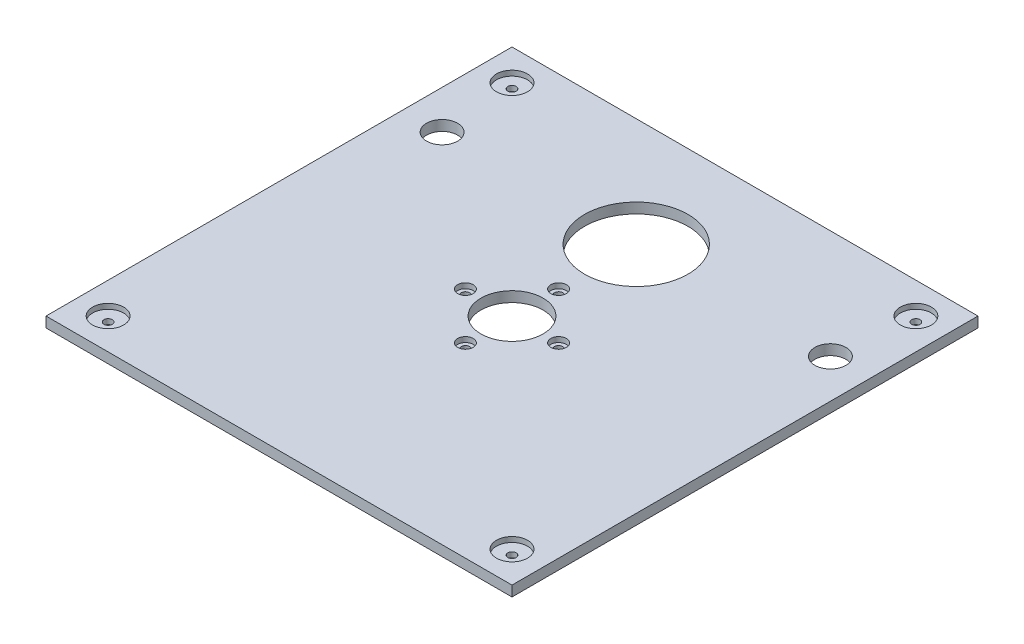
from build123d import *

# Parameters (mm, degrees)
CROQUIS1_W              = 450
CROQUIS1_H              = 450
CROQUIS1_R              = 30
CROQUIS1_R_2            = 50
CROQUIS1_R_3            = 15
SALIENTE_EXTRUIR1_DEPTH = 10
CROQUIS7_R              = 15
CROQUIS7_R_2            = 7.5
CORTAR_EXTRUIR6_DEPTH   = 5
CROQUIS8_R              = 4
CORTAR_EXTRUIR7_DEPTH   = 5


with BuildPart() as part:
    # Croquis1 → Saliente-Extruir1 (new body)
    with BuildSketch(Plane(origin=(0, 0, 0), x_dir=(1, 0, 0), z_dir=(0, 1, 0))):
        Rectangle(CROQUIS1_W, CROQUIS1_H)
        Circle(CROQUIS1_R, mode=Mode.SUBTRACT)
        with Locations((0, 120)):
            Circle(CROQUIS1_R_2, mode=Mode.SUBTRACT)
        with Locations((-187.5, 120)):
            Circle(CROQUIS1_R_3, mode=Mode.SUBTRACT)
        with Locations((187.5, 120)):
            Circle(CROQUIS1_R_3, mode=Mode.SUBTRACT)
    extrude(amount=SALIENTE_EXTRUIR1_DEPTH)

    # Croquis7 → Cortar-Extruir6 (cut)
    with BuildSketch(Plane(origin=(0, 10, 0), x_dir=(1, 0, 0), z_dir=(0, 1, 0))):
        with Locations((-195, 195)):
            Circle(CROQUIS7_R)
        with Locations((195, 195)):
            Circle(CROQUIS7_R)
        with Locations((195, -195)):
            Circle(CROQUIS7_R)
        with Locations((-195, -195)):
            Circle(CROQUIS7_R)
        with Locations((-45, 0)):
            Circle(CROQUIS7_R_2)
        with Locations((0, 45)):
            Circle(CROQUIS7_R_2)
        with Locations((0, -45)):
            Circle(CROQUIS7_R_2)
        with Locations((45, 0)):
            Circle(CROQUIS7_R_2)
    extrude(amount=-CORTAR_EXTRUIR6_DEPTH, mode=Mode.SUBTRACT)

    # Croquis8 → Cortar-Extruir7 (cut)
    with BuildSketch(Plane(origin=(0, 5, 0), x_dir=(1, 0, 0), z_dir=(0, 1, 0))):
        with Locations((195, -195)):
            Circle(CROQUIS8_R)
        with Locations((-195, -195)):
            Circle(CROQUIS8_R)
        with Locations((-45, 0)):
            Circle(CROQUIS8_R)
        with Locations((45, 0)):
            Circle(CROQUIS8_R)
        with Locations((0, -45)):
            Circle(CROQUIS8_R)
        with Locations((0, 45)):
            Circle(CROQUIS8_R)
        with Locations((195, 195)):
            Circle(CROQUIS8_R)
        with Locations((-195, 195)):
            Circle(CROQUIS8_R)
    extrude(amount=-CORTAR_EXTRUIR7_DEPTH, mode=Mode.SUBTRACT)


solid = part.part
